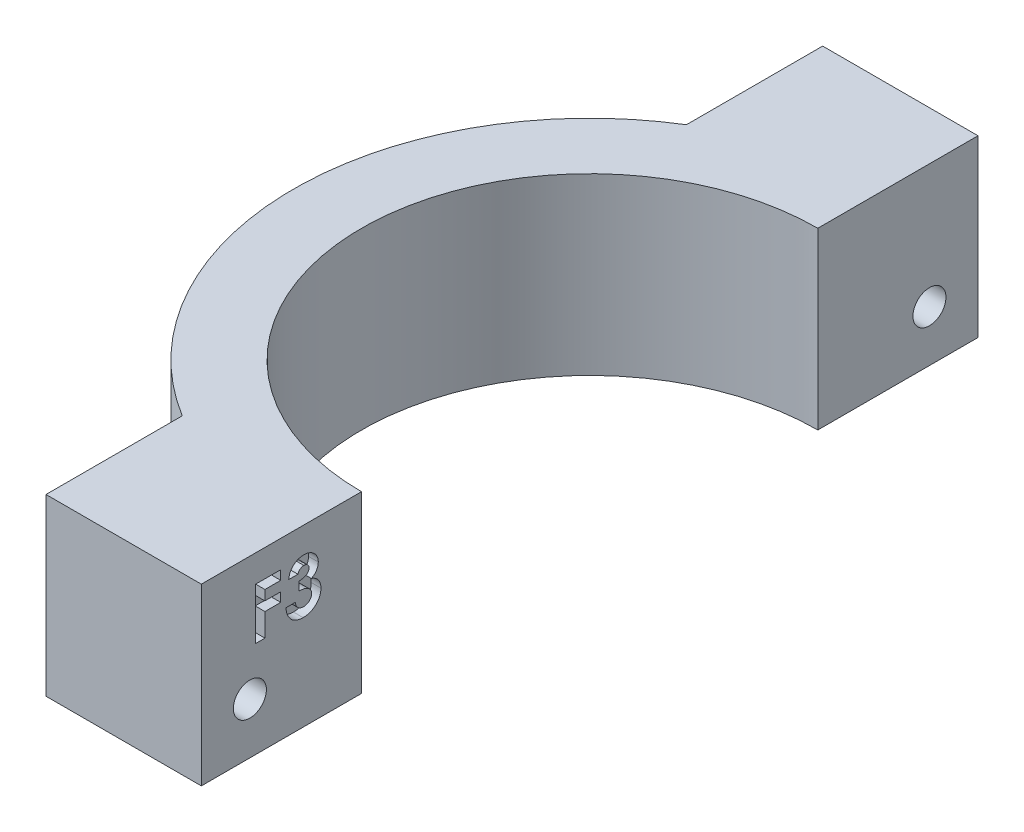
from build123d import *

# Parameters (mm, degrees)
BOSS_EXTRUDE1_DEPTH = 18
SKETCH2_R           = 1.7
CUT_EXTRUDE1_DEPTH  = 31.5
CUT_EXTRUDE2_DEPTH  = 1
CUT_EXTRUDE3_DEPTH  = 5


with BuildPart() as part:
    # Sketch1 → Boss-Extrude1 (new body)
    with BuildSketch(Plane(origin=(0, 0, 0), x_dir=(1, 0, 0), z_dir=(0, 1, 0))):
        with BuildLine():
            Line((-16.998275301, 32.528571429), (-32.998275301, 32.528571429))
            Line((-32.998275301, 32.528571429), (-32.998275301, 18.494895774))
            ThreePointArc((-32.998275301, 18.494895774), (-47.498275301, -7.471428571), (-32.998275301, -33.437752917))
            Line((-32.998275301, -33.437752917), (-32.998275301, -47.471428571))
            Line((-32.998275301, -47.471428571), (-16.998275301, -47.471428571))
            Line((-16.998275301, -47.471428571), (-16.998275301, -30.971428571))
            ThreePointArc((-16.998275301, -30.971428571), (-40.498275301, -7.471428571), (-16.998275301, 16.028571429))
            Line((-16.998275301, 16.028571429), (-16.998275301, 32.528571429))
        make_face()
    extrude(amount=BOSS_EXTRUDE1_DEPTH)

    # Sketch2 → Cut-Extrude1 (cut, through all)
    with BuildSketch(Plane(origin=(-16.998275301, 0, 0), x_dir=(0, 0, -1), z_dir=(1, 0, 0))):
        with Locations((-42.471428571, 5.25)):
            Circle(SKETCH2_R)
        with Locations((27.528571429, 5.25)):
            Circle(SKETCH2_R)
    extrude(amount=-CUT_EXTRUDE1_DEPTH, mode=Mode.SUBTRACT)

    # Sketch3 → Cut-Extrude2 (cut)
    with BuildSketch(Plane(origin=(-16.998275301, 0, 0), x_dir=(0, 0, -1), z_dir=(1, 0, 0))):
        Polygon((-41.871148795, 15.201025034), (-39.293157342, 15.201025034), (-39.293157342, 14.251238709), (-40.92136247, 14.251238709), (-40.92136247, 13.233610504), (-39.293157342, 13.233610504), (-39.293157342, 12.283824179), (-40.92136247, 12.283824179), (-40.92136247, 9.909358367), (-41.871148795, 9.909358367), align=None)
        with BuildLine():
            Line((-37.529268453, 13.912029308), (-38.479054777, 13.912029308))
            add(Edge.make_bspline(
                [(-38.479054777, 13.912029308), (-38.472348925, 13.959505738), (-38.459202545, 14.052580134), (-38.427745016, 14.187328674), (-38.390118416, 14.315146885), (-38.34314353, 14.435629995), (-38.288049629, 14.548992623), (-38.225396959, 14.655623774), (-38.154508221, 14.755065768), (-38.100171252, 14.814970019), (-38.073063525, 14.844855162)],
                knots=[0, 0, 0, 0, 0.000143778, 0.000281867, 0.000414671, 0.000543215, 0.000669322, 0.0007924, 0.000913902, 0.001034861, 0.001034861, 0.001034861, 0.001034861], degree=3))
            add(Edge.make_bspline(
                [(-38.073063525, 14.844855162), (-38.033964221, 14.884286443), (-37.956903602, 14.962001353), (-37.82812627, 15.061545568), (-37.693143844, 15.147694317), (-37.549249192, 15.215993668), (-37.398681424, 15.27127408), (-37.240243172, 15.308406058), (-37.074581872, 15.333043453), (-36.961538875, 15.335470322), (-36.903851118, 15.336708795)],
                knots=[0, 0, 0, 0, 0.000166428, 0.000328012, 0.000487119, 0.000645947, 0.000804887, 0.000967376, 0.001133328, 0.001306272, 0.001306272, 0.001306272, 0.001306272], degree=3))
            add(Edge.make_bspline(
                [(-36.903851118, 15.336708795), (-36.852563734, 15.335498), (-36.751743072, 15.333117822), (-36.603562067, 15.314011042), (-36.462283879, 15.280499879), (-36.326415158, 15.236684784), (-36.197954088, 15.177067025), (-36.07406541, 15.107863497), (-35.958210577, 15.022982493), (-35.850118512, 14.927075501), (-35.750815335, 14.8233427), (-35.664818348, 14.712460867), (-35.590885195, 14.597391911), (-35.529974057, 14.477179826), (-35.483141668, 14.3516212), (-35.450638602, 14.221441367), (-35.429364556, 14.08692758), (-35.427245105, 13.99550037), (-35.426170162, 13.949130336)],
                knots=[0, 0, 0, 0, 0.000153836, 0.00030241, 0.000447173, 0.000588968, 0.00072986, 0.000871333, 0.001014032, 0.001159723, 0.001304436, 0.001444171, 0.001580024, 0.001714184, 0.00184768, 0.001981114, 0.002116187, 0.002255197, 0.002255197, 0.002255197, 0.002255197], degree=3))
            add(Edge.make_bspline(
                [(-35.426170162, 13.949130336), (-35.428376009, 13.89170491), (-35.432718642, 13.778651902), (-35.468353097, 13.613190424), (-35.524130708, 13.454979724), (-35.604706892, 13.306233407), (-35.705447645, 13.167356277), (-35.829053175, 13.042991412), (-35.972002875, 12.931188942), (-36.079317119, 12.87110628), (-36.134269788, 12.840339604)],
                knots=[0, 0, 0, 0, 0.00017212, 0.000338852, 0.000505492, 0.00067385, 0.000844528, 0.001018431, 0.001198237, 0.00138694, 0.00138694, 0.00138694, 0.00138694], degree=3))
            add(Edge.make_bspline(
                [(-36.134269788, 12.840339604), (-36.096551119, 12.827955771), (-36.022435626, 12.803622094), (-35.917089364, 12.755697192), (-35.816917106, 12.703323219), (-35.723643783, 12.642478468), (-35.636341679, 12.575623232), (-35.555542998, 12.502186007), (-35.480764986, 12.422326922), (-35.413228364, 12.335606781), (-35.353286974, 12.243412505), (-35.299504756, 12.147873726), (-35.255238993, 12.047541582), (-35.21774038, 11.943561934), (-35.189191072, 11.835000267), (-35.169089807, 11.722277248), (-35.157470783, 11.605650007), (-35.155698684, 11.526635122), (-35.154802641, 11.486682085)],
                knots=[0, 0, 0, 0, 0.000119012, 0.000233852, 0.000346714, 0.000457856, 0.00056747, 0.000676282, 0.000785032, 0.000895296, 0.001005549, 0.001114686, 0.001223822, 0.001334132, 0.001445978, 0.001560132, 0.001677317, 0.001797176, 0.001797176, 0.001797176, 0.001797176], degree=3))
            add(Edge.make_bspline(
                [(-35.154802641, 11.486682085), (-35.156619041, 11.427967343), (-35.160200611, 11.31219383), (-35.182970562, 11.141671293), (-35.225364107, 10.979093204), (-35.281135164, 10.822588857), (-35.355527701, 10.674178666), (-35.443075211, 10.53045682), (-35.55068869, 10.396407552), (-35.670282595, 10.268486948), (-35.803098598, 10.152187262), (-35.947092752, 10.051360668), (-36.09909875, 9.964833512), (-36.260078289, 9.8945883), (-36.429975443, 9.840491454), (-36.608411526, 9.801387759), (-36.796136276, 9.777463472), (-36.924273105, 9.774955464), (-36.989713498, 9.773674607)],
                knots=[0, 0, 0, 0, 0.000176169, 0.00034737, 0.00051474, 0.000679386, 0.000844836, 0.001011921, 0.001183269, 0.001359492, 0.001536793, 0.001711778, 0.001885991, 0.002060677, 0.00223768, 0.002420033, 0.00260805, 0.002804296, 0.002804296, 0.002804296, 0.002804296], degree=3))
            add(Edge.make_bspline(
                [(-36.989713498, 9.773674607), (-37.051619054, 9.775025054), (-37.172667177, 9.777665676), (-37.349725391, 9.800521596), (-37.518002464, 9.837390049), (-37.677927841, 9.889359191), (-37.828882784, 9.956754287), (-37.972236212, 10.037006724), (-38.105127537, 10.134745277), (-38.229037432, 10.245557842), (-38.341217201, 10.369883248), (-38.441479496, 10.504841559), (-38.527613517, 10.650945966), (-38.599972501, 10.80757225), (-38.657990763, 10.974995181), (-38.703755398, 11.152874295), (-38.735722744, 11.341557113), (-38.745458467, 11.471374906), (-38.750422299, 11.537563496)],
                knots=[0, 0, 0, 0, 0.000185653, 0.000363021, 0.000534566, 0.000701839, 0.000866512, 0.001029812, 0.001193709, 0.001360353, 0.001527707, 0.001695195, 0.001863902, 0.002035591, 0.002211932, 0.002394731, 0.002586078, 0.002785121, 0.002785121, 0.002785121, 0.002785121], degree=3))
            Line((-38.750422299, 11.537563496), (-37.800635974, 11.537563496))
            add(Edge.make_bspline(
                [(-37.800635974, 11.537563496), (-37.794617277, 11.504283004), (-37.782894287, 11.439460519), (-37.760029312, 11.345611971), (-37.730233061, 11.258983964), (-37.695781181, 11.178806552), (-37.658567964, 11.104027033), (-37.613605499, 11.037407199), (-37.564188399, 10.977138049), (-37.492879164, 10.905489419), (-37.3909377, 10.831873443), (-37.253282951, 10.767897658), (-37.100155079, 10.730399988), (-36.993103425, 10.725825387), (-36.937772058, 10.723460932)],
                knots=[0, 0, 0, 0, 0.000101453, 0.000197607, 0.000289457, 0.000375893, 0.000459333, 0.000539595, 0.000616416, 0.00069287, 0.00084235, 0.000990791, 0.001145821, 0.001311674, 0.001311674, 0.001311674, 0.001311674], degree=3))
            add(Edge.make_bspline(
                [(-36.937772058, 10.723460932), (-36.90841128, 10.72396442), (-36.850900082, 10.724950642), (-36.766424697, 10.735881586), (-36.685949998, 10.753884861), (-36.609326097, 10.778350644), (-36.536065202, 10.809020032), (-36.467567036, 10.848566373), (-36.402435434, 10.89454464), (-36.341378437, 10.946236417), (-36.284960514, 11.002561951), (-36.238017483, 11.06493291), (-36.19511495, 11.128312952), (-36.163383928, 11.196848623), (-36.135580716, 11.266851971), (-36.11856373, 11.340863899), (-36.105714684, 11.417331835), (-36.104967949, 11.469663134), (-36.104588966, 11.49622235)],
                knots=[0, 0, 0, 0, 8.804e-05, 0.00017245, 0.000255004, 0.000335125, 0.000413489, 0.000492771, 0.000571884, 0.000652369, 0.000732575, 0.000810392, 0.000886249, 0.00096163, 0.001036443, 0.001111772, 0.00118898, 0.001268546, 0.001268546, 0.001268546, 0.001268546], degree=3))
            add(Edge.make_bspline(
                [(-36.104588966, 11.49622235), (-36.105595096, 11.525269377), (-36.10759807, 11.583095353), (-36.123962582, 11.667480206), (-36.149805605, 11.748651634), (-36.18570472, 11.82625017), (-36.233643988, 11.899989803), (-36.290211789, 11.971349973), (-36.35986473, 12.036616511), (-36.436283336, 12.101130505), (-36.524898897, 12.15736725), (-36.621395711, 12.209265504), (-36.728309865, 12.250560491), (-36.843031489, 12.287444563), (-36.967730649, 12.314384117), (-37.101633011, 12.333944858), (-37.244522568, 12.348504799), (-37.343018198, 12.350593662), (-37.393584692, 12.35166606)],
                knots=[0, 0, 0, 0, 8.7084e-05, 0.000173364, 0.000256838, 0.000342201, 0.000428949, 0.000520167, 0.000614623, 0.000714788, 0.000819753, 0.000928812, 0.001042981, 0.001163003, 0.001290052, 0.001425126, 0.001568892, 0.001720568, 0.001720568, 0.001720568, 0.001720568], degree=3))
            Line((-37.393584692, 12.35166606), (-37.393584692, 13.233610504))
            add(Edge.make_bspline(
                [(-37.393584692, 13.233610504), (-37.330626399, 13.238972234), (-37.212843901, 13.249002968), (-37.049355478, 13.272460189), (-36.911719301, 13.303814627), (-36.796627281, 13.34164206), (-36.701062242, 13.390222338), (-36.617577152, 13.44385282), (-36.545675843, 13.506136787), (-36.484909592, 13.57521694), (-36.436298482, 13.649402546), (-36.40189437, 13.727540541), (-36.379175692, 13.80721324), (-36.377023099, 13.861706965), (-36.375956487, 13.888708661)],
                knots=[0, 0, 0, 0, 0.000189544, 0.000354599, 0.000494992, 0.000612655, 0.000716948, 0.000815736, 0.000909673, 0.001001315, 0.001090992, 0.001174513, 0.001256793, 0.001337606, 0.001337606, 0.001337606, 0.001337606], degree=3))
            add(Edge.make_bspline(
                [(-36.375956487, 13.888708661), (-36.377796698, 13.923159894), (-36.3813884, 13.990401408), (-36.409283508, 14.086638178), (-36.457706253, 14.172425283), (-36.522632653, 14.247582201), (-36.601747728, 14.310358892), (-36.694484465, 14.355933699), (-36.798830471, 14.382710933), (-36.872243509, 14.38548683), (-36.910211295, 14.38692247)],
                knots=[0, 0, 0, 0, 0.000103264, 0.00020155, 0.000297405, 0.00039663, 0.000497784, 0.000598286, 0.000704469, 0.000818208, 0.000818208, 0.000818208, 0.000818208], degree=3))
            add(Edge.make_bspline(
                [(-36.910211295, 14.38692247), (-36.944624824, 14.385228566), (-37.012911806, 14.381867343), (-37.112767812, 14.356780059), (-37.20759775, 14.314548739), (-37.295437959, 14.256314238), (-37.375020447, 14.18637707), (-37.440334709, 14.103551012), (-37.494660015, 14.012798316), (-37.517687082, 13.945750658), (-37.529268453, 13.912029308)],
                knots=[0, 0, 0, 0, 0.000103172, 0.000204725, 0.000306758, 0.000413189, 0.000519795, 0.000623097, 0.000728547, 0.000835248, 0.000835248, 0.000835248, 0.000835248], degree=3))
        make_face()
    extrude(amount=-CUT_EXTRUDE2_DEPTH, mode=Mode.SUBTRACT)

    # Sketch4 → Cut-Extrude3 (cut)
    with BuildSketch(Plane.ZY.offset(32.998275301)):
        Polygon((-25.528765418, 2.783401278), (-24.392531269, 5.748583447), (-26.39233728, 8.215182169), (-29.528377439, 7.716598722), (-30.664611588, 4.751416553), (-28.664805577, 2.284817831), align=None)
        Polygon((44.362800811, 2.699305117), (45.626081257, 5.612628966), (43.734709018, 8.163323849), (40.580056332, 7.800694883), (39.316775886, 4.887371034), (41.208148125, 2.336676151), align=None)
    extrude(amount=-CUT_EXTRUDE3_DEPTH, mode=Mode.SUBTRACT)


solid = part.part
